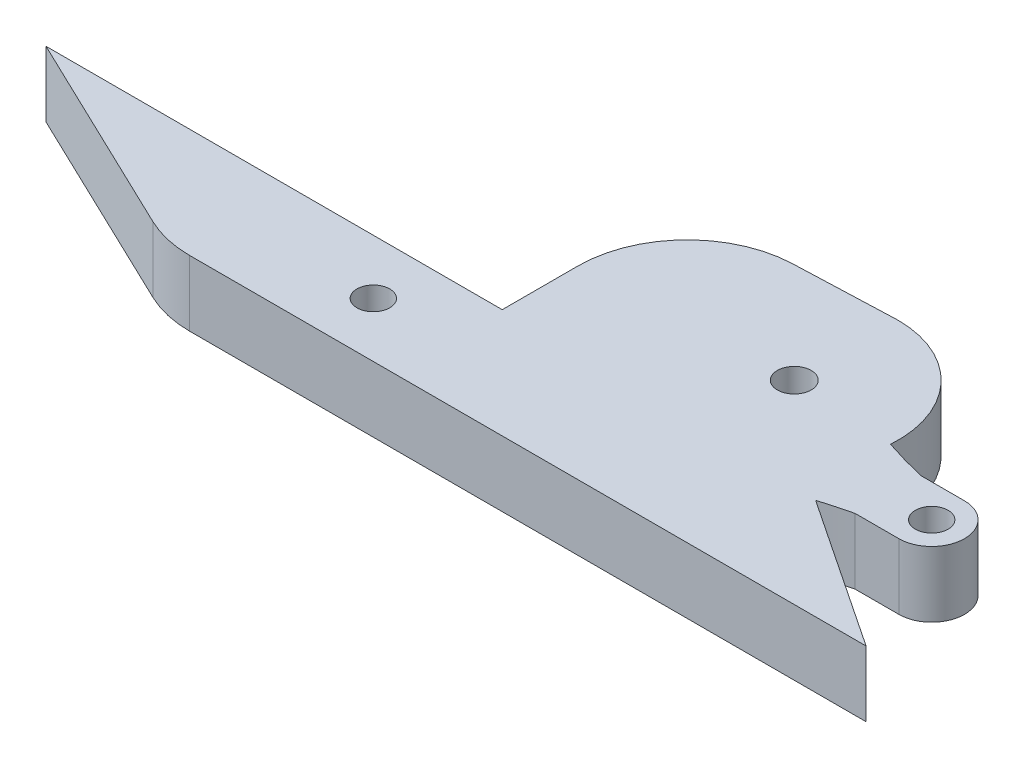
from build123d import *

# Parameters (mm, degrees)
SKETCH1_R           = 1.5
SKETCH1_R_2         = 1.55
BOSS_EXTRUDE1_DEPTH = 6


with BuildPart() as part:
    # Sketch1 → Boss-Extrude1 (new body)
    with BuildSketch(Plane(origin=(0, 0, 0), x_dir=(1, 0, 0), z_dir=(0, 1, 0))):
        with BuildLine():
            Line((-10.054576391, 17.239228809), (-18.654572416, 16.912740777))
            ThreePointArc((-18.654572416, 16.912740777), (-25.479153077, 13.855584783), (-28.275208275, 6.919939226))
            Line((-28.275208275, 6.919939226), (-28.275208275, 0))
            Line((-28.275208275, 0), (-49.137604137, 0))
            Line((-49.137604137, 0), (-70, 0))
            Line((-70, 0), (-51.187164382, -9.017581558))
            ThreePointArc((-51.187164382, -9.017581558), (-49.081079033, -9.751302876), (-46.864755002, -10))
            Line((-46.864755002, -10), (0, -10))
            Line((0, -10), (15, -10))
            Line((15, -10), (1.155446716, -0.770297811))
            add(Edge.make_bspline(
                [(1.155446716, -0.770297811), (2.094509546, -0.481388498), (3.042693974, -0.224622561), (4, 0)],
                knots=[0.265250857, 0.265250857, 0.265250857, 0.265250857, 1, 1, 1, 1], degree=3))
            Line((4, 0), (8, 0))
            ThreePointArc((8, 0), (11, 3), (8, 6))
            Line((8, 6), (4, 6))
            add(Edge.make_bspline(
                [(0.141983447, 7.095761644), (2.045647207, 6.458569901), (4, 6)],
                knots=[0, 0, 0, 1, 1, 1], degree=2))
            ThreePointArc((0.141983447, 7.095761644), (-2.383666412, 14.242578452), (-9.33430338, 17.266573068))
            Line((-9.33430338, 17.266573068), (-10.054576391, 17.239228809))
        make_face()
        with Locations((-35.063841459, -5)):
            Circle(SKETCH1_R, mode=Mode.SUBTRACT)
        with Locations((8, 3)):
            Circle(SKETCH1_R, mode=Mode.SUBTRACT)
        with Locations((-9.33430338, 7.766573068)):
            Circle(SKETCH1_R_2, mode=Mode.SUBTRACT)
    extrude(amount=BOSS_EXTRUDE1_DEPTH)


solid = part.part
